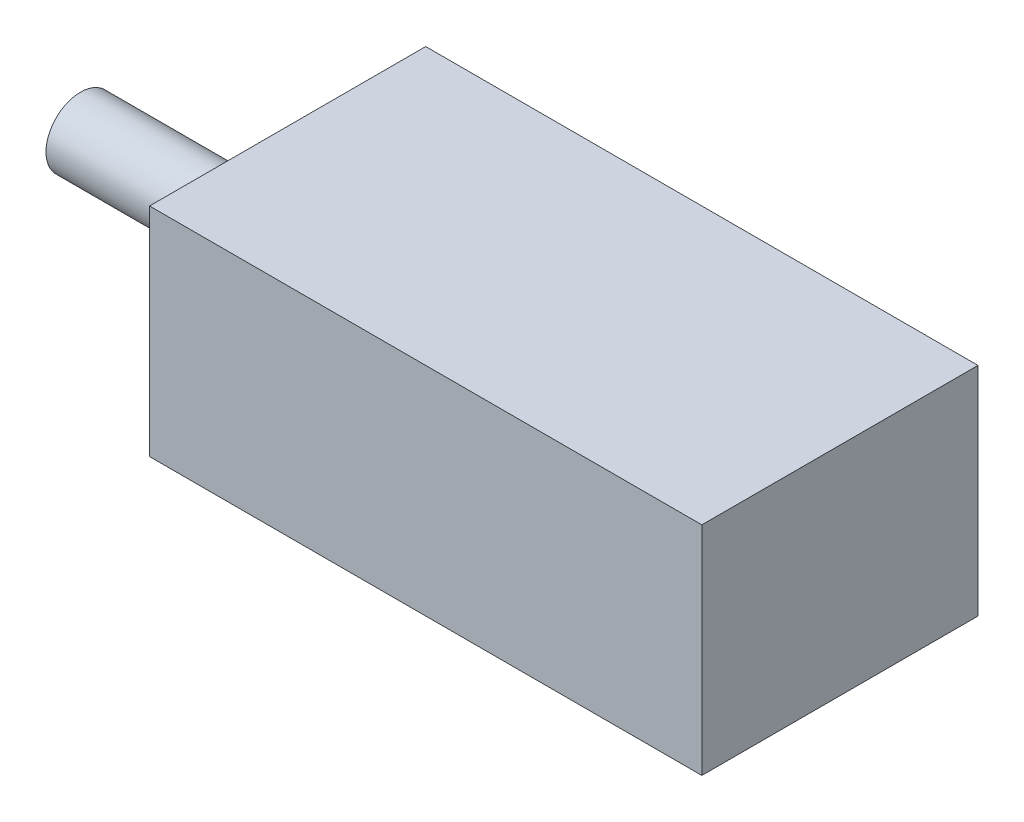
from build123d import *

# Parameters (mm, degrees)
SKETCH1_W           = 25.4
SKETCH1_H           = 12.7
BOSS_EXTRUDE1_DEPTH = 9.9822
SKETCH3_R           = 1.5875
BOSS_EXTRUDE2_DEPTH = 9.525


with BuildPart() as part:
    # Sketch1 → Boss-Extrude1 (new body)
    with BuildSketch(Plane(origin=(0, 0, 0), x_dir=(1, 0, 0), z_dir=(0, 1, 0))):
        with Locations((12.7, 6.35)):
            Rectangle(SKETCH1_W, SKETCH1_H)
    extrude(amount=BOSS_EXTRUDE1_DEPTH)

    # Sketch3 → Boss-Extrude2 (add)
    with BuildSketch(Plane.ZY):
        with Locations((-6.35, 4.9911)):
            Circle(SKETCH3_R)
    extrude(amount=BOSS_EXTRUDE2_DEPTH)


solid = part.part
